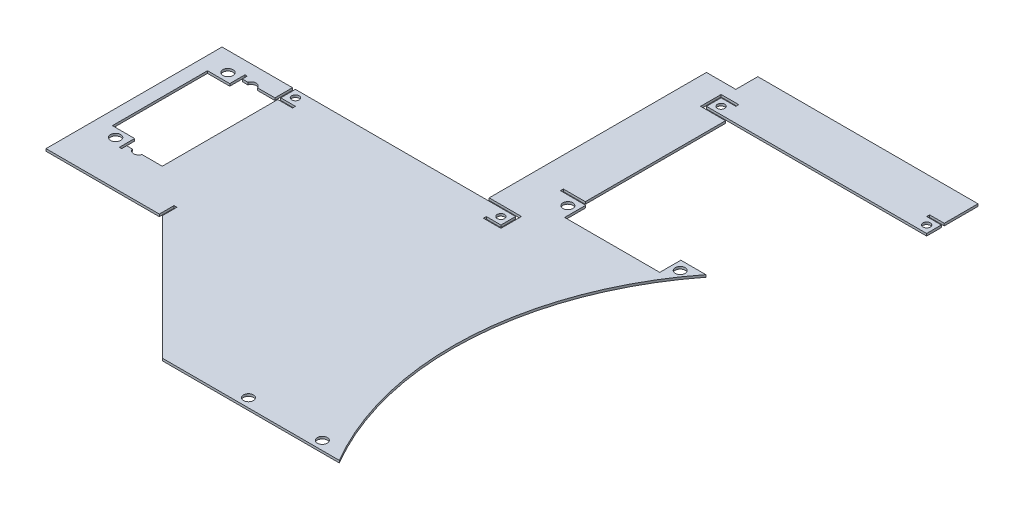
from build123d import *

# Parameters (mm, degrees)
SKETCH2_W                    = 254
SKETCH2_H                    = 254
BOSS_EXTRUDE1_DEPTH          = 1.00076
SKETCH3_W                    = 69.85
SKETCH3_H                    = 25.4
CUT_EXTRUDE1_DEPTH           = 1
CUT_EXTRUDE1_DEPTH_BACK      = 2.00076
CUT_EXTRUDE2_DEPTH           = 1
CUT_EXTRUDE2_DEPTH_BACK      = 2.00076
SKETCH5_R                    = 2.150000018
CUT_EXTRUDE3_DEPTH           = 1
CUT_EXTRUDE3_DEPTH_BACK      = 2.00076
SKETCH6_R                    = 2.099999991
CUT_EXTRUDE4_DEPTH           = 1
CUT_EXTRUDE4_DEPTH_BACK      = 2.00076
SKETCH7_W                    = 95.25
SKETCH7_H                    = 95.25
CUT_EXTRUDE5_DEPTH           = 1
CUT_EXTRUDE5_DEPTH_BACK      = 2.00076
CUT_EXTRUDE6_DEPTH           = 1
CUT_EXTRUDE6_DEPTH_BACK      = 2.00076
BOSS_EXTRUDE4_DEPTH          = 1.00076
SKETCH18_W                   = 12.7
SKETCH18_H                   = 1.27
CUT_EXTRUDE_THIN4_DEPTH      = 1
CUT_EXTRUDE_THIN4_DEPTH_BACK = 2.00076
CUT_EXTRUDE7_DEPTH           = 1
CUT_EXTRUDE7_DEPTH_BACK      = 2.00076
SKETCH10_W                   = 9.525
SKETCH10_H                   = 60.6472
SKETCH10_W_2                 = 95.25
SKETCH10_H_2                 = 9.525
BOSS_EXTRUDE2_DEPTH          = 1.00076
SKETCH14_R                   = 2.200000045
BOSS_EXTRUDE3_DEPTH          = 1.00076
SKETCH15_W                   = 1.27
SKETCH15_H                   = 6.35
CUT_EXTRUDE_THIN3_DEPTH      = 1
CUT_EXTRUDE_THIN3_DEPTH_BACK = 2.00076
SKETCH19_R                   = 1.5875
CUT_EXTRUDE8_DEPTH           = 1
CUT_EXTRUDE8_DEPTH_BACK      = 2.00076
SKETCH20_W                   = 1.27
SKETCH20_H                   = 1.27
SKETCH20_W_2                 = 6.35
CUT_EXTRUDE12_DEPTH          = 1
CUT_EXTRUDE12_DEPTH_BACK     = 2.00076


with BuildPart() as part:
    # Sketch2 → Boss-Extrude1 (new body)
    with BuildSketch(Plane(origin=(0, 0, 0), x_dir=(1, 0, 0), z_dir=(0, 1, 0))):
        Rectangle(SKETCH2_W, SKETCH2_H)
    extrude(amount=BOSS_EXTRUDE1_DEPTH)

    # Sketch3 → Cut-Extrude1 (cut, two sides)
    with BuildSketch(Plane(origin=(0, 1.00076, 0), x_dir=(1, 0, 0), z_dir=(0, 1, 0))) as cut_extrude1_sk:
        with Locations((92.075, 34.552)):
            Rectangle(SKETCH3_W, SKETCH3_H)
    extrude(amount=CUT_EXTRUDE1_DEPTH, mode=Mode.SUBTRACT)
    extrude(cut_extrude1_sk.sketch, amount=-CUT_EXTRUDE1_DEPTH_BACK, mode=Mode.SUBTRACT)

    # Sketch4 → Cut-Extrude2 (cut, two sides)
    with BuildSketch(Plane(origin=(0, 1.00076, 0), x_dir=(1, 0, 0), z_dir=(0, 1, 0))) as cut_extrude2_sk:
        with BuildLine():
            Line((127, -127), (127, 21.852))
            Line((127, 21.852), (122.640015225, 21.852))
            ThreePointArc((122.640015225, 21.852), (94.909945844, -51.086516198), (112.96892893, -127))
            Line((112.96892893, -127), (127, -127))
        make_face()
    extrude(amount=CUT_EXTRUDE2_DEPTH, mode=Mode.SUBTRACT)
    extrude(cut_extrude2_sk.sketch, amount=-CUT_EXTRUDE2_DEPTH_BACK, mode=Mode.SUBTRACT)

    # Sketch5 → Cut-Extrude3 (cut, two sides)
    with BuildSketch(Plane(origin=(0, 1.00076, 0), x_dir=(1, 0, 0), z_dir=(0, 1, 0))) as cut_extrude3_sk:
        with Locations((69.85, -123.19)):
            Circle(SKETCH5_R)
        with Locations((101.802396213, -123.19)):
            Circle(SKETCH5_R)
        with Locations((66.977000031, 17.859999967)):
            Circle(SKETCH5_R)
        with Locations((115.577000113, 17.859999967)):
            Circle(SKETCH5_R)
    extrude(amount=CUT_EXTRUDE3_DEPTH, mode=Mode.SUBTRACT)
    extrude(cut_extrude3_sk.sketch, amount=-CUT_EXTRUDE3_DEPTH_BACK, mode=Mode.SUBTRACT)

    # Sketch6 → Cut-Extrude4 (cut, two sides)
    with BuildSketch(Plane(origin=(0, 1.00076, 0), x_dir=(1, 0, 0), z_dir=(0, 1, 0))) as cut_extrude4_sk:
        with Locations((66.977000031, 27.860000033)):
            Circle(SKETCH6_R)
        with Locations((66.977000031, 17.859999967)):
            Circle(SKETCH6_R)
        with Locations((115.577000113, 27.860000033)):
            Circle(SKETCH6_R)
        with Locations((115.577000113, 17.859999967)):
            Circle(SKETCH6_R)
        Polygon((70.700000078, 22.36), (70.700000078, 12.733000061), (111.854000066, 12.733000061), (111.854000066, 22.36), (118.458000066, 22.36), (118.458000066, 23.36), (111.854000066, 23.36), (111.854000066, 32.986999939), (70.700000078, 32.986999939), (70.700000078, 23.36), (64.096000078, 23.36), (64.096000078, 22.36), align=None)
    extrude(amount=CUT_EXTRUDE4_DEPTH, mode=Mode.SUBTRACT)
    extrude(cut_extrude4_sk.sketch, amount=-CUT_EXTRUDE4_DEPTH_BACK, mode=Mode.SUBTRACT)

    # Sketch7 → Cut-Extrude5 (cut, two sides)
    with BuildSketch(Plane(origin=(0, 1.00076, 0), x_dir=(1, 0, 0), z_dir=(0, 1, 0))) as cut_extrude5_sk:
        with Locations((12.1158, 50.1142)):
            Rectangle(SKETCH7_W, SKETCH7_H)
    extrude(amount=CUT_EXTRUDE5_DEPTH, mode=Mode.SUBTRACT)
    extrude(cut_extrude5_sk.sketch, amount=-CUT_EXTRUDE5_DEPTH_BACK, mode=Mode.SUBTRACT)

    # Sketch8 → Cut-Extrude6 (cut, two sides)
    with BuildSketch(Plane(origin=(0, 1.00076, 0), x_dir=(1, 0, 0), z_dir=(0, 1, 0))) as cut_extrude6_sk:
        Polygon((127, 47.252), (127, 127), (-127, 127), (-127, -127), (-35.5092, -127), (-35.5092, 47.252), align=None)
    extrude(amount=CUT_EXTRUDE6_DEPTH, mode=Mode.SUBTRACT)
    extrude(cut_extrude6_sk.sketch, amount=-CUT_EXTRUDE6_DEPTH_BACK, mode=Mode.SUBTRACT)

    # Sketch17 → Boss-Extrude4 (add)
    with BuildSketch(Plane(origin=(0, 1.00076, 0), x_dir=(1, 0, 0), z_dir=(0, 1, 0))):
        Polygon((59.7408, 2.4892), (47.0408, 2.4892), (47.0408, 97.7392), (59.7408, 97.7392), (154.9908, 97.7392), (154.9908, 85.0392), (59.7408, 85.0392), align=None)
    extrude(amount=-BOSS_EXTRUDE4_DEPTH)

    # Sketch18 → Cut-Extrude-Thin4 (cut, two sides)
    with BuildSketch(Plane(origin=(0, 1.00076, 0), x_dir=(1, 0, 0), z_dir=(0, 1, 0))) as cut_extrude_thin4_sk:
        with Locations((53.3908, 3.1242)):
            Rectangle(SKETCH18_W, SKETCH18_H)
    extrude(amount=CUT_EXTRUDE_THIN4_DEPTH, mode=Mode.SUBTRACT)
    extrude(cut_extrude_thin4_sk.sketch, amount=-CUT_EXTRUDE_THIN4_DEPTH_BACK, mode=Mode.SUBTRACT)

    # Sketch9 → Cut-Extrude7 (cut, two sides)
    with BuildSketch(Plane(origin=(0, 1.00076, 0), x_dir=(1, 0, 0), z_dir=(0, 1, 0))) as cut_extrude7_sk:
        Polygon((-35.5092, -55.113847322), (36.376952678, -127), (-35.5092, -127), align=None)
    extrude(amount=CUT_EXTRUDE7_DEPTH, mode=Mode.SUBTRACT)
    extrude(cut_extrude7_sk.sketch, amount=-CUT_EXTRUDE7_DEPTH_BACK, mode=Mode.SUBTRACT)

    # Sketch10 → Boss-Extrude2 (add)
    with BuildSketch(Plane(origin=(0, 1.00076, 0), x_dir=(1, 0, 0), z_dir=(0, 1, 0))):
        with Locations((64.5033, 53.4456)):
            Rectangle(SKETCH10_W, SKETCH10_H)
        with Locations((107.3658, 102.5017)):
            Rectangle(SKETCH10_W_2, SKETCH10_H_2)
    extrude(amount=-BOSS_EXTRUDE2_DEPTH)

    # Sketch14 → Boss-Extrude3 (add)
    with BuildSketch(Plane(origin=(0, 1.00076, 0), x_dir=(1, 0, 0), z_dir=(0, 1, 0))):
        with BuildLine():
            Line((-61.511199939, -50.699323655), (-61.511199939, -9.545323667))
            Line((-61.511199939, -9.545323667), (-51.8842, -9.545323667))
            Line((-51.8842, -9.545323667), (-51.8842, -2.941323667))
            Line((-51.8842, -2.941323667), (-50.8842, -2.941323667))
            Line((-50.8842, -2.941323667), (-50.8842, -5.1308))
            Line((-50.8842, -5.1308), (-48.472691116, -5.1308))
            ThreePointArc((-48.472691116, -5.1308), (-46.384199967, -3.622323575), (-44.295708818, -5.1308))
            Line((-44.295708818, -5.1308), (-35.5092, -5.1308))
            Line((-35.5092, -5.1308), (-35.5092, 2.4892))
            Line((-35.5092, 2.4892), (-67.2592, 2.4892))
            Line((-67.2592, 2.4892), (-67.2592, -73.66))
            Line((-67.2592, -73.66), (-16.963047322, -73.66))
            Line((-16.963047322, -73.66), (-35.5092, -55.113847322))
            Line((-35.5092, -55.113847322), (-44.295708818, -55.113847322))
            ThreePointArc((-44.295708818, -55.113847322), (-46.384199967, -56.622323747), (-48.472691116, -55.113847322))
            Line((-48.472691116, -55.113847322), (-50.8842, -55.113847322))
            Line((-50.8842, -55.113847322), (-50.8842, -57.303323655))
            Line((-50.8842, -57.303323655), (-51.8842, -57.303323655))
            Line((-51.8842, -57.303323655), (-51.8842, -50.699323655))
            Line((-51.8842, -50.699323655), (-61.511199939, -50.699323655))
        make_face()
        with Locations((-56.384200033, -54.422323702)):
            Circle(SKETCH14_R, mode=Mode.SUBTRACT)
        with Locations((-56.384200033, -5.82232362)):
            Circle(SKETCH14_R, mode=Mode.SUBTRACT)
    extrude(amount=-BOSS_EXTRUDE3_DEPTH)

    # Sketch15 → Cut-Extrude-Thin3 (cut, two sides)
    with BuildSketch(Plane(origin=(0, 1.00076, 0), x_dir=(1, 0, 0), z_dir=(0, 1, 0))) as cut_extrude_thin3_sk:
        with Locations((-17.598047322, -70.485)):
            Rectangle(SKETCH15_W, SKETCH15_H)
    extrude(amount=CUT_EXTRUDE_THIN3_DEPTH, mode=Mode.SUBTRACT)
    extrude(cut_extrude_thin3_sk.sketch, amount=-CUT_EXTRUDE_THIN3_DEPTH_BACK, mode=Mode.SUBTRACT)

    # Sketch19 → Cut-Extrude8 (cut, two sides)
    with BuildSketch(Plane(origin=(0, 1.00076, 0), x_dir=(1, 0, 0), z_dir=(0, 1, 0))) as cut_extrude8_sk:
        with Locations((56.5658, -0.6858)):
            Circle(SKETCH19_R)
        with Locations((-32.3342, -0.6858)):
            Circle(SKETCH19_R)
        with Locations((151.8158, 88.2142)):
            Circle(SKETCH19_R)
        with Locations((62.9158, 88.2142)):
            Circle(SKETCH19_R)
    extrude(amount=CUT_EXTRUDE8_DEPTH, mode=Mode.SUBTRACT)
    extrude(cut_extrude8_sk.sketch, amount=-CUT_EXTRUDE8_DEPTH_BACK, mode=Mode.SUBTRACT)

    # Sketch20 → Cut-Extrude12 (cut, two sides)
    with BuildSketch(Plane(origin=(0, 1.00076, 0), x_dir=(1, 0, 0), z_dir=(0, 1, 0))) as cut_extrude12_sk:
        with Locations((59.1058, 84.4042)):
            Rectangle(SKETCH20_W, SKETCH20_H)
        Polygon((59.7408, 91.3892), (66.0908, 91.3892), (66.0908, 92.6592), (58.4708, 92.6592), (58.4708, 85.0392), (59.7408, 85.0392), align=None)
        with Locations((60.3758, 3.1242)):
            Rectangle(SKETCH20_W, SKETCH20_H)
        Polygon((59.7408, -3.8608), (53.3908, -3.8608), (53.3908, -5.1308), (61.0108, -5.1308), (61.0108, 2.4892), (59.7408, 2.4892), align=None)
        Polygon((-29.1592, -3.8608), (-29.1592, -5.1308), (-36.7792, -5.1308), (-36.7792, 2.4892), (-35.5092, 2.4892), (-35.5092, -3.8608), align=None)
        with Locations((151.8158, 92.0242)):
            Rectangle(SKETCH20_W_2, SKETCH20_H)
    extrude(amount=CUT_EXTRUDE12_DEPTH, mode=Mode.SUBTRACT)
    extrude(cut_extrude12_sk.sketch, amount=-CUT_EXTRUDE12_DEPTH_BACK, mode=Mode.SUBTRACT)


solid = part.part
